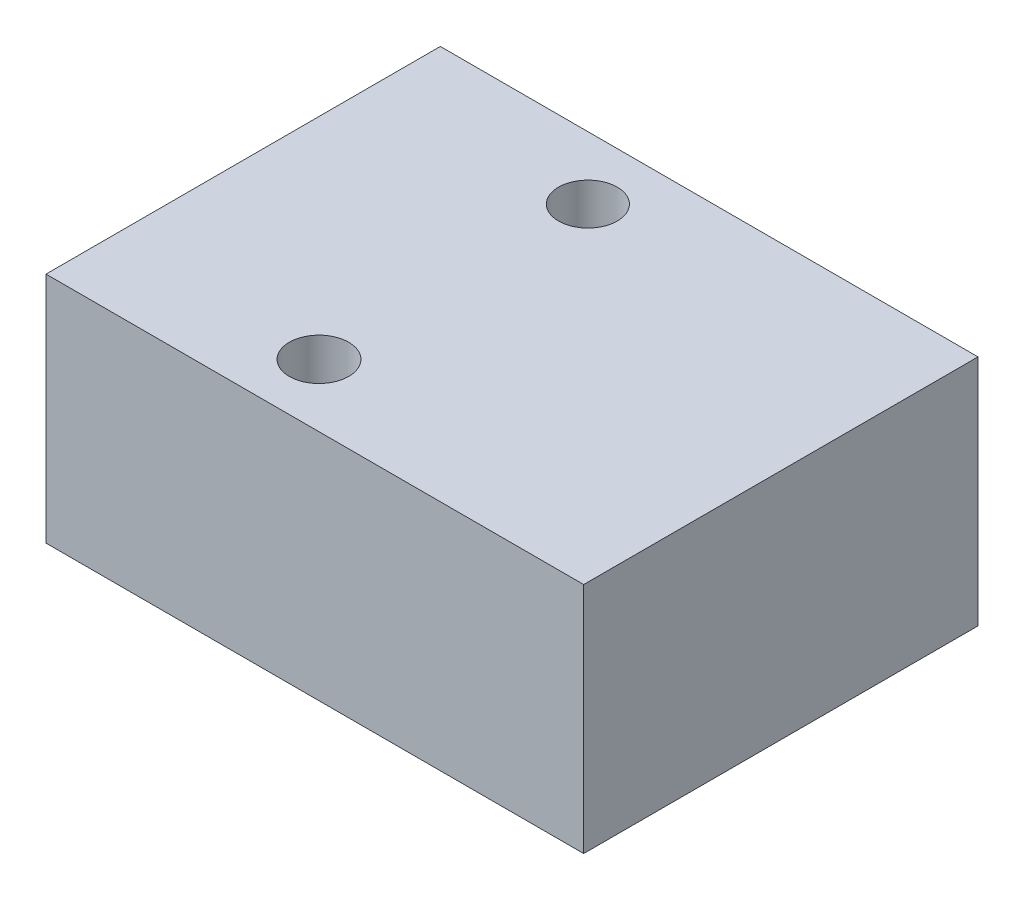
from build123d import *

# Parameters (mm, degrees)
SKETCH1_W           = 30
SKETCH1_H           = 22
BOSS_EXTRUDE1_DEPTH = 13
SKETCH2_R           = 1.639627053
SKETCH2_R_2         = 1.655795528
CUT_EXTRUDE1_DEPTH  = 20


with BuildPart() as part:
    # Sketch1 → Boss-Extrude1 (new body)
    with BuildSketch(Plane(origin=(0, 0, 0), x_dir=(1, 0, 0), z_dir=(0, 1, 0))):
        with Locations((0, 3.598214286)):
            Rectangle(SKETCH1_W, SKETCH1_H)
    extrude(amount=BOSS_EXTRUDE1_DEPTH)

    # Sketch2 → Cut-Extrude1 (cut)
    with BuildSketch(Plane(origin=(0, 13, 0), x_dir=(1, 0, 0), z_dir=(0, 1, 0))):
        with Locations((-3.26527347, 11.097173048)):
            Circle(SKETCH2_R)
        with Locations((-3.26527347, -3.9052047)):
            Circle(SKETCH2_R_2)
    extrude(amount=-CUT_EXTRUDE1_DEPTH, mode=Mode.SUBTRACT)


solid = part.part
